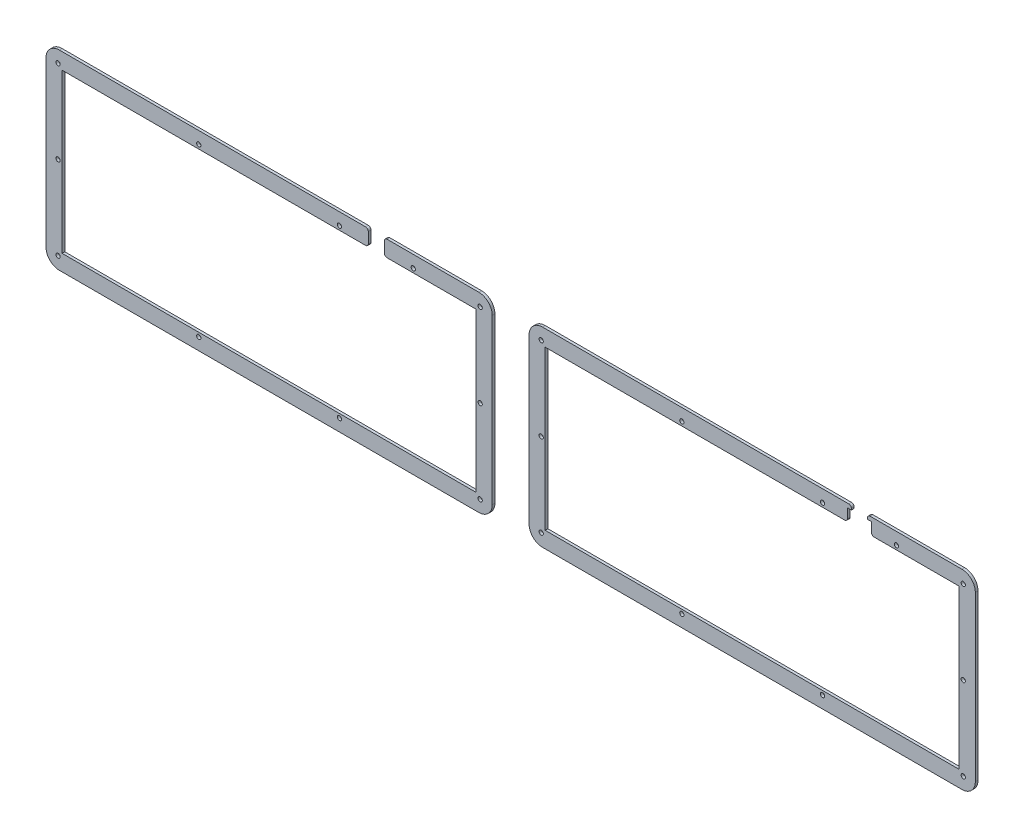
from build123d import *

# Parameters (mm, degrees)
SKETCH_1_R        = 1.6
SKETCH_1_R_2      = 1.5998
SKETCH_1_R_3      = 1.59992
EXTRUDE_1_DEPTH   = 2
EXTRUDE_1_2_DEPTH = 2


with BuildPart() as part:
    # 草图1 → 凸台-拉伸1 (new body)
    with BuildSketch(Plane.XY):
        with BuildLine():
            Line((-119.24661957, 73.609909265), (-119.24661957, 67.609909265))
            Line((-119.24661957, 67.609909265), (-119.24661957, 66.609909265))
            ThreePointArc((-119.24661957, 66.609909265), (-119.832406007, 65.195695703), (-121.24661957, 64.609909265))
            Line((-121.24661957, 64.609909265), (-347.64756957, 64.609909265))
            Line((-347.64756957, 64.609909265), (-347.64756957, -53.690820735))
            Line((-347.64756957, -53.690820735), (-38.84561957, -53.690820735))
            Line((-38.84561957, -53.690820735), (-38.84561957, 64.609909265))
            Line((-38.84561957, 64.609909265), (-105.24661957, 64.609909265))
            ThreePointArc((-105.24661957, 64.609909265), (-106.660833132, 65.195695703), (-107.24661957, 66.609909265))
            Line((-107.24661957, 66.609909265), (-107.24661957, 67.609909265))
            Line((-107.24661957, 67.609909265), (-107.24661957, 73.609909265))
            Line((-107.24661957, 73.609909265), (-107.24661957, 74.609909265))
            ThreePointArc((-107.24661957, 74.609909265), (-106.660833132, 76.024122827), (-105.24661957, 76.609909265))
            Line((-105.24661957, 76.609909265), (-36.84561957, 76.609909265))
            ThreePointArc((-36.84561957, 76.609909265), (-29.774551758, 73.680977077), (-26.84561957, 66.609909265))
            Line((-26.84561957, 66.609909265), (-26.84561957, -55.692176735))
            ThreePointArc((-26.84561957, -55.692176735), (-29.774551758, -62.763244547), (-36.84561957, -65.692176735))
            Line((-36.84561957, -65.692176735), (-349.64753497, -65.692176735))
            ThreePointArc((-349.64753497, -65.692176735), (-356.718602782, -62.763244547), (-359.64753497, -55.692176735))
            Line((-359.64753497, -55.692176735), (-359.64753497, 66.609909265))
            ThreePointArc((-359.64753497, 66.609909265), (-356.718602782, 73.680977077), (-349.64753497, 76.609909265))
            Line((-349.64753497, 76.609909265), (-121.24661957, 76.609909265))
            ThreePointArc((-121.24661957, 76.609909265), (-119.832406007, 76.024122827), (-119.24661957, 74.609909265))
            Line((-119.24661957, 74.609909265), (-119.24661957, 73.609909265))
        make_face()
        with Locations((-140.78061957, 67.609909265)):
            Circle(SKETCH_1_R, mode=Mode.SUBTRACT)
        with Locations((-85.71261957, 67.609909265)):
            Circle(SKETCH_1_R, mode=Mode.SUBTRACT)
        with Locations((-245.71361957, 67.609909265)):
            Circle(SKETCH_1_R, mode=Mode.SUBTRACT)
        with Locations((-350.64754957, 67.609909265)):
            Circle(SKETCH_1_R, mode=Mode.SUBTRACT)
        with Locations((-350.64754957, 5.458809265)):
            Circle(SKETCH_1_R_2, mode=Mode.SUBTRACT)
        with Locations((-350.64754957, -56.692190735)):
            Circle(SKETCH_1_R_3, mode=Mode.SUBTRACT)
        with Locations((-245.71361957, -56.692190735)):
            Circle(SKETCH_1_R_3, mode=Mode.SUBTRACT)
        with Locations((-140.78061957, -56.692190735)):
            Circle(SKETCH_1_R_3, mode=Mode.SUBTRACT)
        with Locations((-35.84561957, -56.692190735)):
            Circle(SKETCH_1_R_3, mode=Mode.SUBTRACT)
        with Locations((-35.84561957, 5.458809265)):
            Circle(SKETCH_1_R_2, mode=Mode.SUBTRACT)
        with Locations((-35.84561957, 67.609909265)):
            Circle(SKETCH_1_R, mode=Mode.SUBTRACT)
    extrude(amount=EXTRUDE_1_DEPTH)


with BuildPart() as body_2:
    # 草图1 → Extrude 1 2 (new body)
    with BuildSketch(Plane.XY):
        with BuildLine():
            Line((12.67711533, 65.854986568), (12.67711533, -52.445743432))
            Line((12.67711533, -52.445743432), (321.47906533, -52.445743432))
            Line((321.47906533, -52.445743432), (321.47906533, 65.854986568))
            Line((321.47906533, 65.854986568), (258.07806533, 65.854986568))
            ThreePointArc((258.07806533, 65.854986568), (256.663851768, 66.440773005), (256.07806533, 67.854986568))
            Line((256.07806533, 67.854986568), (256.07806533, 74.854986568))
            Line((256.07806533, 74.854986568), (253.07806533, 74.854986568))
            Line((253.07806533, 74.854986568), (253.07806533, 75.854986568))
            ThreePointArc((253.07806533, 75.854986568), (253.663851768, 77.26920013), (255.07806533, 77.854986568))
            Line((255.07806533, 77.854986568), (258.07806533, 77.854986568))
            Line((258.07806533, 77.854986568), (323.47906533, 77.854986568))
            ThreePointArc((323.47906533, 77.854986568), (330.550133142, 74.926054379), (333.47906533, 67.854986568))
            Line((333.47906533, 67.854986568), (333.47906533, -54.447099432))
            ThreePointArc((333.47906533, -54.447099432), (330.550133142, -61.518167244), (323.47906533, -64.447099432))
            Line((323.47906533, -64.447099432), (10.67714993, -64.447099432))
            ThreePointArc((10.67714993, -64.447099432), (3.606082118, -61.518167244), (0.67714993, -54.447099432))
            Line((0.67714993, -54.447099432), (0.67714993, 67.854986568))
            ThreePointArc((0.67714993, 67.854986568), (3.606082118, 74.926054379), (10.67714993, 77.854986568))
            Line((10.67714993, 77.854986568), (236.07806533, 77.854986568))
            Line((236.07806533, 77.854986568), (239.07806533, 77.854986568))
            ThreePointArc((239.07806533, 77.854986568), (240.492278892, 77.26920013), (241.07806533, 75.854986568))
            Line((241.07806533, 75.854986568), (241.07806533, 74.854986568))
            Line((241.07806533, 74.854986568), (238.07806533, 74.854986568))
            Line((238.07806533, 74.854986568), (238.07806533, 67.854986568))
            ThreePointArc((238.07806533, 67.854986568), (237.492278892, 66.440773005), (236.07806533, 65.854986568))
            Line((236.07806533, 65.854986568), (12.67711533, 65.854986568))
        make_face()
        with Locations((219.54406533, 68.854986568)):
            Circle(SKETCH_1_R, mode=Mode.SUBTRACT)
        with Locations((274.61206533, 68.854986568)):
            Circle(SKETCH_1_R, mode=Mode.SUBTRACT)
        with Locations((114.61106533, 68.854986568)):
            Circle(SKETCH_1_R, mode=Mode.SUBTRACT)
        with Locations((9.67713533, 68.854986568)):
            Circle(SKETCH_1_R, mode=Mode.SUBTRACT)
        with Locations((9.67713533, 6.703886568)):
            Circle(SKETCH_1_R_2, mode=Mode.SUBTRACT)
        with Locations((9.67713533, -55.447113432)):
            Circle(SKETCH_1_R_3, mode=Mode.SUBTRACT)
        with Locations((114.61106533, -55.447113432)):
            Circle(SKETCH_1_R_3, mode=Mode.SUBTRACT)
        with Locations((219.54406533, -55.447113432)):
            Circle(SKETCH_1_R_3, mode=Mode.SUBTRACT)
        with Locations((324.47906533, -55.447113432)):
            Circle(SKETCH_1_R_3, mode=Mode.SUBTRACT)
        with Locations((324.47906533, 6.703886568)):
            Circle(SKETCH_1_R_2, mode=Mode.SUBTRACT)
        with Locations((324.47906533, 68.854986568)):
            Circle(SKETCH_1_R, mode=Mode.SUBTRACT)
    extrude(amount=EXTRUDE_1_2_DEPTH)


solid = Compound([part.part, body_2.part])
